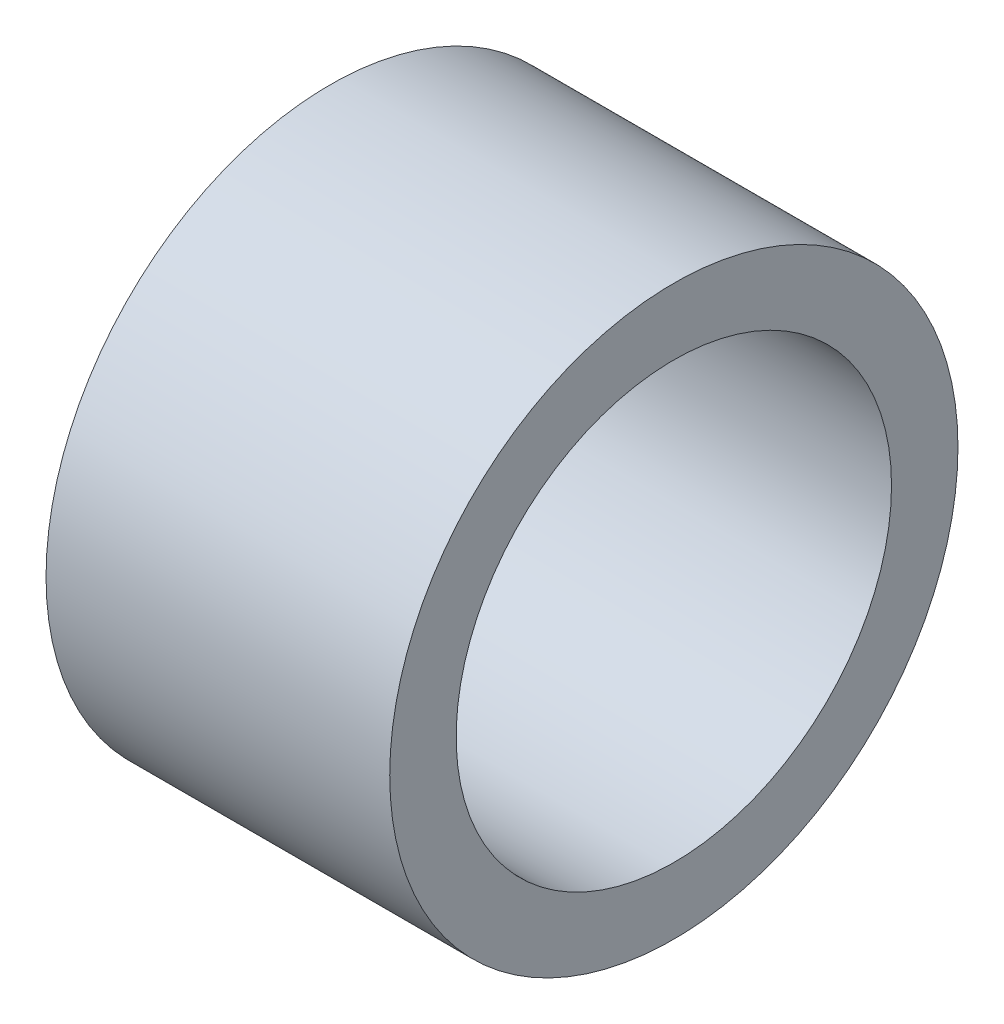
from build123d import *


with BuildPart() as part:
    # Sketch1 → Base-Revolve (revolve)
    with BuildSketch(Plane.XY):
        Polygon((0, 4.75), (0, 6.2), (-4, 6.2), (-7.5, 6.2), (-7.5, 4.75), align=None)
    revolve(axis=Axis((0, 0, 0), (-1, 0, 0)))


solid = part.part
